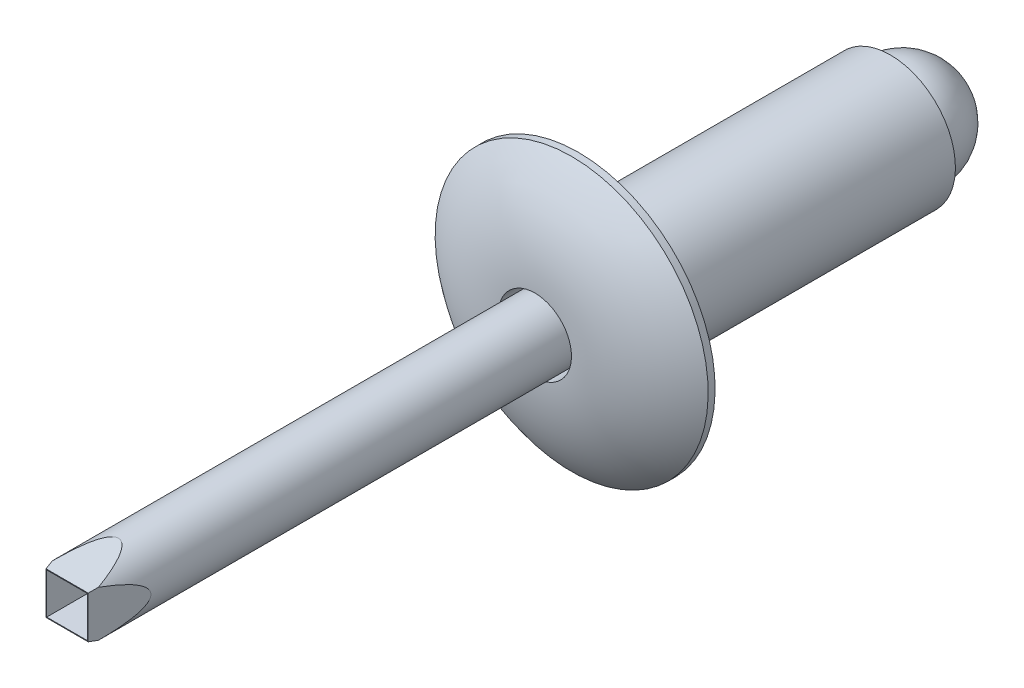
from build123d import *

# Parameters (mm, degrees)
SKETCH7_W          = 19.8882
SKETCH7_H          = 1.190625
CUT_EXTRUDE1_DEPTH = 6.0038001
CIRPATTERN1_COUNT  = 2
CIRPATTERN1_ANGLE  = 90
SKETCH9_W          = 1.4970125
SKETCH9_H          = 1.4970125
CUT_EXTRUDE3_DEPTH = 2.54
FILLET2_R          = 0.254


with BuildPart() as part:
    # Sketch2 → Revolve1 (revolve)
    with BuildSketch(Plane(origin=(0, 0, 0), x_dir=(0, 0, -1), z_dir=(1, 0, 0))):
        with BuildLine():
            Line((11.43, 2.38125), (0, 2.38125))
            Line((0, 2.38125), (0, 5.0038))
            Line((0, 5.0038), (-0.254, 5.0038))
            ThreePointArc((-0.254, 5.0038), (-1.253001484, 3.29135556), (-1.6002, 1.339453125))
            Line((-1.6002, 1.339453125), (0, 1.339453125))
            Line((0, 1.339453125), (1.143, 1.339453125))
            Line((1.143, 1.339453125), (1.143, 0))
            Line((1.143, 0), (11.43, 0))
            Line((11.43, 0), (11.43, 2.38125))
        make_face()
    revolve(axis=Axis((0, 0, -11.43), (0, 0, 1)))

    # Fillet2
    fillet2_edges = [part.edges().sort_by_distance(p)[0] for p in [
        (0, -2.38125, 0),
    ]]
    fillet(fillet2_edges, radius=FILLET2_R)


with BuildPart() as body_2:
    # Sketch7 → Revolve2 (revolve)
    with BuildSketch(Plane(origin=(0, 0, 0), x_dir=(0, 0, -1), z_dir=(1, 0, 0))):
        with Locations((-8.8011, 0.5953125)):
            Rectangle(SKETCH7_W, SKETCH7_H)
    revolve(axis=Axis((0, 0, 18.7452), (0, 0, -1)))

    # Sketch3 → Cut-Extrude1 (cut, symmetric)
    with BuildSketch(Plane(origin=(0, 0, 0), x_dir=(1, 0, 0), z_dir=(0, 1, 0))):
        Polygon((-1.393825, -15.948927223), (-0.77390625, -18.7452), (0.77390625, -18.7452), (1.393825, -15.948927223), (1.393825, -19.2532), (-1.393825, -19.2532), align=None)
    cut_extrude1 = extrude(amount=CUT_EXTRUDE1_DEPTH, both=True, mode=Mode.SUBTRACT)

    # CirPattern1: Cut-Extrude1 ×2 about axis
    cirpattern1_axis = Axis((0, 0, 18.7452), (0, 0, -1))
    for i in range(1, CIRPATTERN1_COUNT):
        add(cut_extrude1.rotate(cirpattern1_axis, i * CIRPATTERN1_ANGLE / (CIRPATTERN1_COUNT - 1)), mode=Mode.SUBTRACT)

    # Sketch9 → Cut-Extrude3 (cut)
    with BuildSketch(Plane.XY.offset(18.7452)):
        Rectangle(SKETCH9_W, SKETCH9_H)
    extrude(amount=-CUT_EXTRUDE3_DEPTH, mode=Mode.SUBTRACT)


with BuildPart() as body_3:
    # Sketch8 → Revolve3 (revolve)
    with BuildSketch(Plane(origin=(0, 0, 0), x_dir=(0, 0, -1), z_dir=(1, 0, 0))):
        with BuildLine():
            Line((11.43, 1.905), (11.43, 0))
            Line((11.43, 0), (13.8303, 0))
            ThreePointArc((13.8303, 0), (13.090224038, 1.532193288), (11.43, 1.905))
        make_face()
    revolve(axis=Axis((0, 0, -11.43), (0, 0, -1)))


solid = Compound([part.part, body_2.part, body_3.part])
